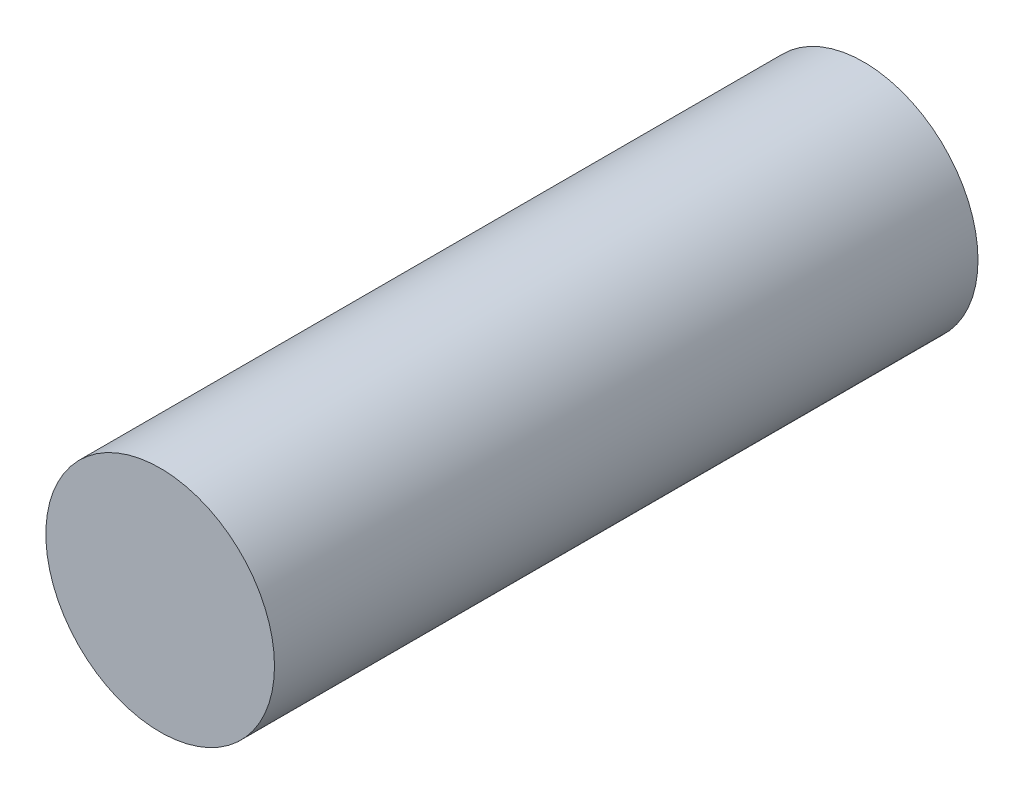
from build123d import *

# Parameters (mm, degrees)
SKETCH_1_R      = 4.875
EXTRUDE_1_DEPTH = 30


with BuildPart() as part:
    # 草图1 → 凸台-拉伸1 (new body)
    with BuildSketch(Plane.XY):
        Circle(SKETCH_1_R)
    extrude(amount=EXTRUDE_1_DEPTH)


solid = part.part
